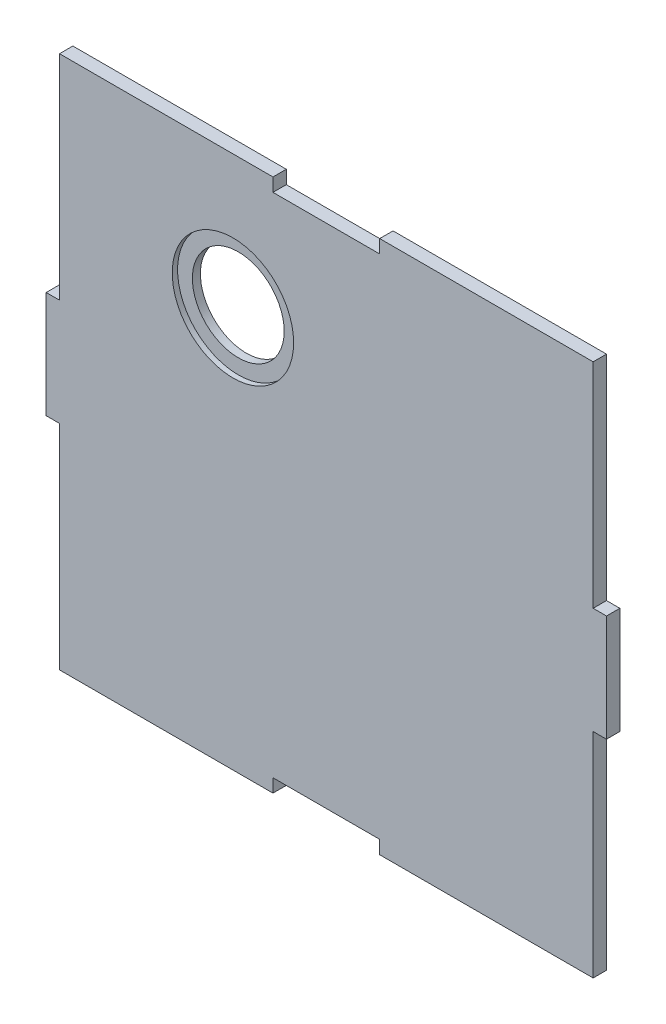
from build123d import *

# Parameters (mm, degrees)
SALIENTE_EXTRUIR1_DEPTH = 5
CROQUIS2_R              = 17.2
CORTAR_EXTRUIR1_DEPTH   = 5
CROQUIS3_R              = 22.75
CORTAR_EXTRUIR2_DEPTH   = 2


with BuildPart() as part:
    # Croquis1 → Saliente-Extruir1 (new body)
    with BuildSketch(Plane.XY):
        Polygon((-100, -100), (-100, -20), (-105, -20), (-105, 20), (-100, 20), (-100, 100), (-20, 100), (-20, 95), (20, 95), (20, 100), (100, 100), (100, 20), (105, 20), (105, -20), (100, -20), (100, -100), (20, -100), (20, -95), (-20, -95), (-20, -100), align=None)
    extrude(amount=SALIENTE_EXTRUIR1_DEPTH)

    # Croquis2 → Cortar-Extruir1 (cut)
    with BuildSketch(Plane.XY.offset(5)):
        with Locations((-35, 50)):
            Circle(CROQUIS2_R)
    extrude(amount=-CORTAR_EXTRUIR1_DEPTH, mode=Mode.SUBTRACT)

    # Croquis3 → Cortar-Extruir2 (cut)
    with BuildSketch(Plane.XY.offset(5)):
        with Locations((-35, 50)):
            Circle(CROQUIS3_R)
    extrude(amount=-CORTAR_EXTRUIR2_DEPTH, mode=Mode.SUBTRACT)


solid = part.part
